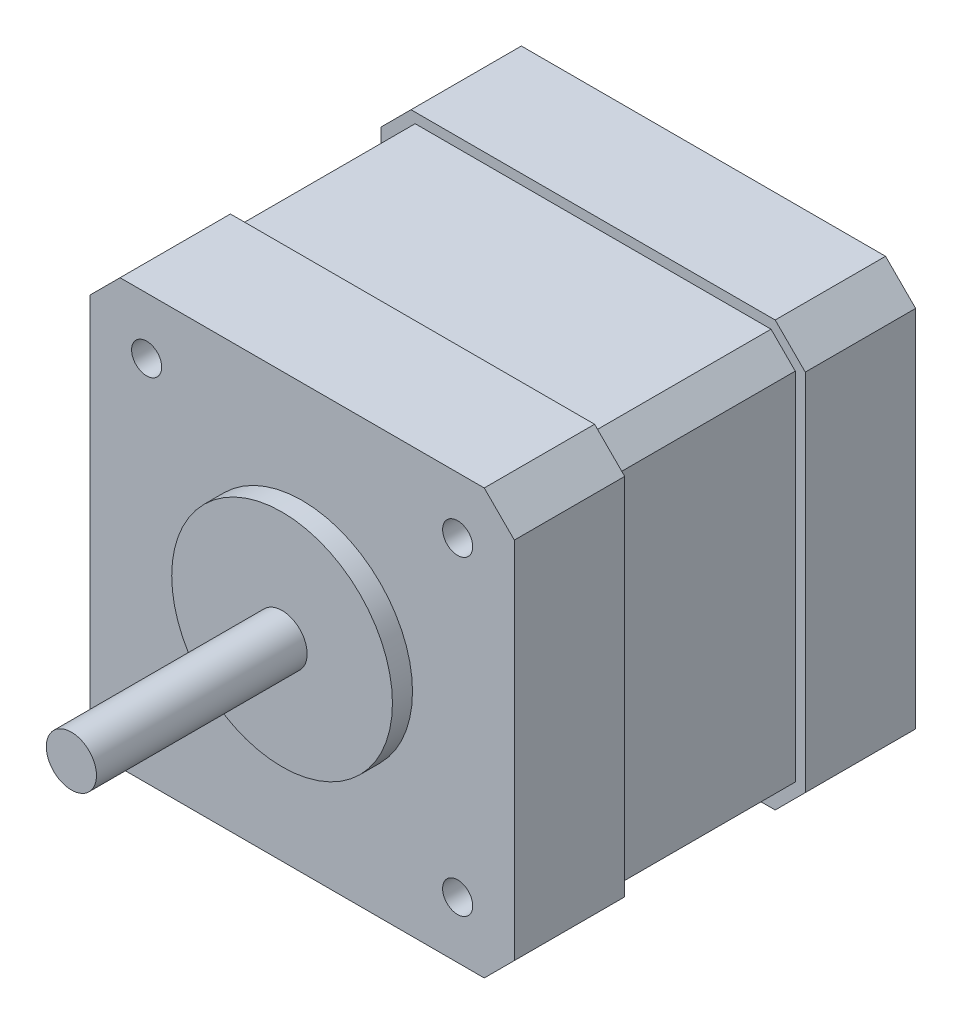
from build123d import *

# Parameters (mm, degrees)
EXTRUDE_1_DEPTH     = 10
SKETCH_2_R          = 11
EXTRUDE_2_DEPTH     = 2
SKETCH_3_R          = 2.5
EXTRUDE_3_DEPTH     = 22
EXTRUDE_4_DEPTH     = 18
EXTRUDE_5_DEPTH     = 10
SKETCH_4_R          = 1.5
CUT_EXTRUDE_1_DEPTH = 46.5
SKETCH_5_R          = 2.5
CUT_EXTRUDE_2_DEPTH = 1
SKETCH_9_R          = 1.5
EXTRUDE_6_DEPTH     = 1
SKETCH_10_R         = 1.5
SKETCH_10_R_2       = 2.5
EXTRUDE_7_DEPTH     = 1
SKETCH_11_R         = 11
SKETCH_11_R_2       = 2.5
EXTRUDE_8_DEPTH     = 1


with BuildPart() as part:
    # Эскиз1 → Бобышка-Вытянуть1 (new body)
    with BuildSketch(Plane.XY):
        Polygon((-32.767753805, -16.536194896), (-32.767753805, 19.763805104), (-29.767753805, 22.763805104), (6.532246195, 22.763805104), (9.532246195, 19.763805104), (9.532246195, -16.536194896), (6.532246195, -19.536194896), (-29.767753805, -19.536194896), align=None)
    extrude(amount=EXTRUDE_1_DEPTH)

    # Эскиз2 → Бобышка-Вытянуть2 (add)
    with BuildSketch(Plane.XY.offset(10)):
        with Locations(Location((-11.617753805, 1.613805104, 0), (0, 0, 180))):
            Circle(SKETCH_2_R)
    extrude(amount=EXTRUDE_2_DEPTH)

    # Эскиз3 → Бобышка-Вытянуть3 (add)
    with BuildSketch(Plane.XY.offset(12)):
        with Locations((-11.617753805, 1.613805104)):
            Circle(SKETCH_3_R)
    extrude(amount=EXTRUDE_3_DEPTH)

    # Эскиз6 → Бобышка-Вытянуть4 (add)
    with BuildSketch(Plane(origin=(0, 0, 0), x_dir=(-1, 0, 0), z_dir=(0, 0, -1))):
        Polygon((11.617753805, 21.763805104), (-6.118032632, 21.763805104), (-8.532246195, 19.349591542), (-8.532246195, -16.121981333), (-6.118032632, -18.536194896), (29.353540243, -18.536194896), (31.767753805, -16.121981333), (31.767753805, 19.349591542), (29.353540243, 21.763805104), align=None)
    extrude(amount=EXTRUDE_4_DEPTH)

    # Эскиз7 → Бобышка-Вытянуть5 (add)
    with BuildSketch(Plane.XY.offset(-18)):
        Polygon((-32.767753805, -16.536194896), (-32.767753805, 19.763805104), (-29.767753805, 22.763805104), (6.532246195, 22.763805104), (9.532246195, 19.763805104), (9.532246195, -16.536194896), (6.532246195, -19.536194896), (-29.767753805, -19.536194896), align=None)
    extrude(amount=-EXTRUDE_5_DEPTH)

    # Эскиз4 → Вырез-Вытянуть1 (cut)
    with BuildSketch(Plane.XY.offset(10)):
        with Locations((-27.117753805, 17.113805104)):
            Circle(SKETCH_4_R)
        with Locations((3.882246195, 17.113805104)):
            Circle(SKETCH_4_R)
        with Locations((3.882246195, -13.886194896)):
            Circle(SKETCH_4_R)
        with Locations((-27.117753805, -13.886194896)):
            Circle(SKETCH_4_R)
    extrude(amount=-CUT_EXTRUDE_1_DEPTH, mode=Mode.SUBTRACT)

    # Эскиз5 → Вырез-Вытянуть2 (cut)
    with BuildSketch(Plane(origin=(0, 0, -28), x_dir=(-1, 0, 0), z_dir=(0, 0, -1))):
        with Locations(Location((11.617753805, 1.613805104, 0), (0, 0, 180))):
            Circle(SKETCH_5_R)
    extrude(amount=-CUT_EXTRUDE_2_DEPTH, mode=Mode.SUBTRACT)

    # Эскиз9 → Бобышка-Вытянуть6 (add)
    with BuildSketch(Plane.XY.offset(10)):
        Polygon((-29.767753805, 22.763805104), (-32.767753805, 19.763805104), (-32.767753805, -16.536194896), (-29.767753805, -19.536194896), (6.532246195, -19.536194896), (9.532246195, -16.536194896), (9.532246195, 19.763805104), (6.532246195, 22.763805104), align=None)
        with Locations((3.882246195, 17.113805104)):
            Circle(SKETCH_9_R, mode=Mode.SUBTRACT)
        with Locations((3.882246195, -13.886194896)):
            Circle(SKETCH_9_R, mode=Mode.SUBTRACT)
        with Locations((-27.117753805, -13.886194896)):
            Circle(SKETCH_9_R, mode=Mode.SUBTRACT)
        with Locations((-27.117753805, 17.113805104)):
            Circle(SKETCH_9_R, mode=Mode.SUBTRACT)
    extrude(amount=EXTRUDE_6_DEPTH)

    # Эскиз10 → Бобышка-Вытянуть7 (add)
    with BuildSketch(Plane(origin=(0, 0, -28), x_dir=(-1, 0, 0), z_dir=(0, 0, -1))):
        Polygon((32.767753805, 19.763805104), (29.767753805, 22.763805104), (-6.532246195, 22.763805104), (-9.532246195, 19.763805104), (-9.532246195, -16.536194896), (-6.532246195, -19.536194896), (29.767753805, -19.536194896), (32.767753805, -16.536194896), align=None)
        with Locations(Location((-3.882246195, -13.886194896, 0), (0, 0, 180))):
            Circle(SKETCH_10_R, mode=Mode.SUBTRACT)
        with Locations(Location((27.117753805, -13.886194896, 0), (0, 0, 180))):
            Circle(SKETCH_10_R, mode=Mode.SUBTRACT)
        with Locations(Location((11.617753805, 1.613805104, 0), (0, 0, 180))):
            Circle(SKETCH_10_R_2, mode=Mode.SUBTRACT)
        with Locations(Location((-3.882246195, 17.113805104, 0), (0, 0, 180))):
            Circle(SKETCH_10_R, mode=Mode.SUBTRACT)
        with Locations(Location((27.117753805, 17.113805104, 0), (0, 0, 180))):
            Circle(SKETCH_10_R, mode=Mode.SUBTRACT)
    extrude(amount=EXTRUDE_7_DEPTH)

    # Эскиз11 → Бобышка-Вытянуть8 (add)
    with BuildSketch(Plane.XY.offset(12)):
        with Locations((-11.617753805, 1.613805104)):
            Circle(SKETCH_11_R)
        with Locations(Location((-11.617753805, 1.613805104, 0), (0, 0, 180))):
            Circle(SKETCH_11_R_2, mode=Mode.SUBTRACT)
    extrude(amount=EXTRUDE_8_DEPTH)


solid = part.part
